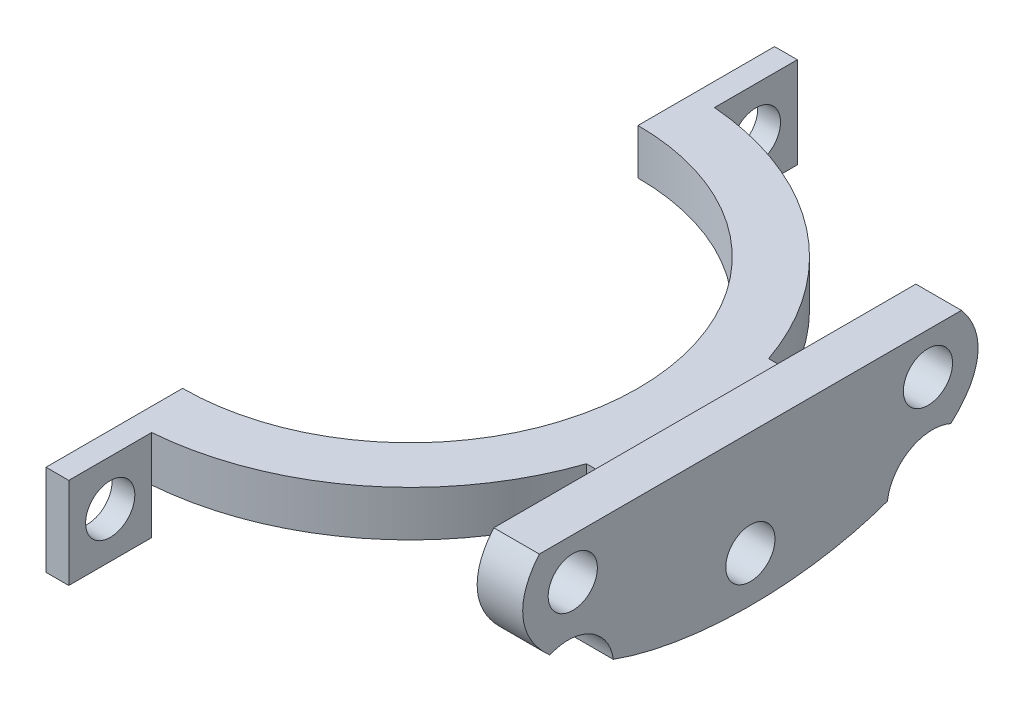
from build123d import *

# Parameters (mm, degrees)
BOSS_EXTRUDE1_DEPTH = 5
SKETCH2_W           = 2.5
SKETCH2_H           = 9.100970889
BOSS_EXTRUDE2_DEPTH = 5
CUT_EXTRUDE1_REACH  = 56.95
SKETCH3_R           = 2.7
SKETCH4_W           = 20
SKETCH4_H           = 5
SKETCH4_R           = 2.7
BOSS_EXTRUDE3_DEPTH = 5
SKETCH5_R           = 5
CUT_EXTRUDE2_DEPTH  = 10


with BuildPart() as part:
    # Sketch1 → Boss-Extrude1 (new body)
    with BuildSketch(Plane(origin=(0, 0, 0), x_dir=(1, 0, 0), z_dir=(0, 1, 0))):
        with BuildLine():
            Line((0, -25), (0, -40))
            Line((0, -40), (2.5, -40))
            Line((2.5, -40), (2.5, -30.899029111))
            ThreePointArc((2.5, -30.899029111), (19.044247329, -24.460511926), (29.342801502, -10))
            Line((29.342801502, -10), (37.342801502, -10))
            Line((37.342801502, -10), (37.342801502, 10))
            Line((37.342801502, 10), (29.342801502, 10))
            ThreePointArc((29.342801502, 10), (19.044247329, 24.460511926), (2.5, 30.899029111))
            Line((2.5, 30.899029111), (2.5, 40))
            Line((2.5, 40), (0, 40))
            Line((0, 40), (0, 25))
            ThreePointArc((0, 25), (25, 0), (0, -25))
        make_face()
    extrude(amount=BOSS_EXTRUDE1_DEPTH)

    # Sketch2 → Boss-Extrude2 (add)
    with BuildSketch(Plane.XZ):
        with Locations((1.25, 35.449514556)):
            Rectangle(SKETCH2_W, SKETCH2_H)
        with Locations((1.25, -35.449514556)):
            Rectangle(SKETCH2_W, SKETCH2_H)
    extrude(amount=BOSS_EXTRUDE2_DEPTH)

    # Sketch3 → Cut-Extrude1 (cut, up to next)
    with BuildSketch(Plane.ZY, mode=Mode.PRIVATE) as cut_extrude1_sk1:
        with Locations((-35.449514555, 0)):
            Circle(SKETCH3_R)
    cut_extrude1_tool1 = extrude(cut_extrude1_sk1.sketch, amount=-CUT_EXTRUDE1_REACH, mode=Mode.PRIVATE) & part.part
    # Sketch3 → Cut-Extrude1 (cut, up to next)
    with BuildSketch(Plane.ZY, mode=Mode.PRIVATE) as cut_extrude1_sk2:
        with Locations((35.449514555, 0)):
            Circle(SKETCH3_R)
    cut_extrude1_tool2 = extrude(cut_extrude1_sk2.sketch, amount=-CUT_EXTRUDE1_REACH, mode=Mode.PRIVATE) & part.part
    add(cut_extrude1_tool1.solids().sort_by_distance((0, 0, -35.449515))[0], mode=Mode.SUBTRACT)
    add(cut_extrude1_tool2.solids().sort_by_distance((0, 0, 35.449515))[0], mode=Mode.SUBTRACT)

    # Sketch4 → Boss-Extrude3 (add)
    with BuildSketch(Plane(origin=(37.342801502, 0, 0), x_dir=(0, 0, -1), z_dir=(1, 0, 0))):
        with BuildLine():
            add(Edge.make_bspline(
                [(-23.175620272, 7), (-37.080992454, -9.500000022), (3e-08, -9.5)],
                knots=[2.757195879, 2.757195879, 2.757195879, 4.712388982, 4.712388982, 4.712388982], degree=2, weights=[1, 0.559016994, 1]))
            add(Edge.make_bspline(
                [(3e-08, -9.5), (25, -9.499999986), (25, 2.5)],
                knots=[4.712388982, 4.712388982, 4.712388982, 6.283185307, 6.283185307, 6.283185307], degree=2, weights=[1, 0.707106782, 1]))
            add(Edge.make_bspline(
                [(25, 2.5), (25, 4.835206052), (23.175620272, 7)],
                knots=[0, 0, 0, 0.384396774, 0.384396774, 0.384396774], degree=2, weights=[1, 0.981586677, 1]))
            Line((23.175620272, 7), (-23.175620272, 7))
        make_face()
        with Locations((0, 2.5)):
            Rectangle(SKETCH4_W, SKETCH4_H, mode=Mode.SUBTRACT)
        with Locations((-19.5, 2.5)):
            Circle(SKETCH4_R, mode=Mode.SUBTRACT)
        with Locations((19.5, 2.5)):
            Circle(SKETCH4_R, mode=Mode.SUBTRACT)
        with Locations((0, -4.5)):
            Circle(SKETCH4_R, mode=Mode.SUBTRACT)
    extrude(amount=-BOSS_EXTRUDE3_DEPTH)

    # Sketch5 → Cut-Extrude2 (cut)
    with BuildSketch(Plane.ZY.offset(-32.342801502)):
        with Locations((-20, -7.759289568)):
            Circle(SKETCH5_R)
        with Locations((20, -7.759289568)):
            Circle(SKETCH5_R)
    extrude(amount=-CUT_EXTRUDE2_DEPTH, mode=Mode.SUBTRACT)


solid = part.part
